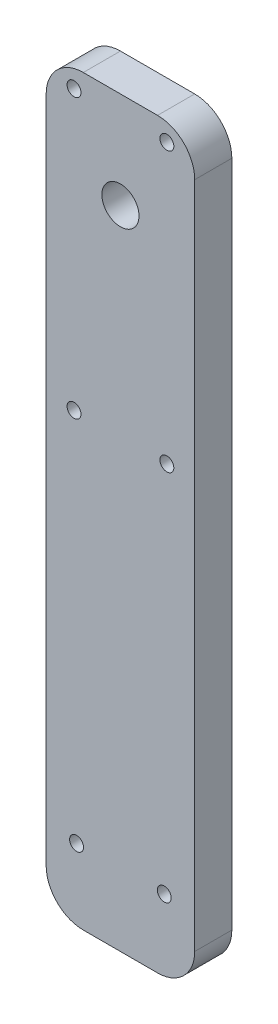
from build123d import *

# Parameters (mm, degrees)
SKETCH1_W           = 25.4
SKETCH1_H           = 127
BOSS_EXTRUDE1_DEPTH = 6.35
SKETCH2_R           = 1.190625
CUT_EXTRUDE1_DEPTH  = 6.35
FILLET1_R           = 6.35
SKETCH3_R           = 3.175
CUT_EXTRUDE2_DEPTH  = 6.35
SKETCH4_R           = 1.190625
CUT_EXTRUDE3_DEPTH  = 6.35


with BuildPart() as part:
    # Sketch1 → Boss-Extrude1 (new body)
    with BuildSketch(Plane.XY):
        with Locations((12.7, 63.5)):
            Rectangle(SKETCH1_W, SKETCH1_H)
    extrude(amount=BOSS_EXTRUDE1_DEPTH)

    # Sketch2 → Cut-Extrude1 (cut)
    with BuildSketch(Plane.XY.offset(6.35)):
        with Locations((5.2, 12.2625)):
            Circle(SKETCH2_R)
        with Locations((20.2, 12.2625)):
            Circle(SKETCH2_R)
    extrude(amount=-CUT_EXTRUDE1_DEPTH, mode=Mode.SUBTRACT)

    # Fillet1
    fillet1_edges = [part.edges().sort_by_distance(p)[0] for p in [
        (0, 127, 3.175),
        (25.4, 127, 3.175),
        (25.4, 0, 3.175),
        (0, 0, 3.175),
    ]]
    fillet(fillet1_edges, radius=FILLET1_R)

    # Sketch3 → Cut-Extrude2 (cut)
    with BuildSketch(Plane.XY.offset(6.35)):
        with Locations((12.7, 110.49991)):
            Circle(SKETCH3_R)
    extrude(amount=-CUT_EXTRUDE2_DEPTH, mode=Mode.SUBTRACT)

    # Sketch4 → Cut-Extrude3 (cut)
    with BuildSketch(Plane.XY.offset(6.35)):
        with Locations((4.7625, 123.8123)):
            Circle(SKETCH4_R)
        with Locations((20.6375, 123.8123)):
            Circle(SKETCH4_R)
        with Locations((20.6375, 76.1873)):
            Circle(SKETCH4_R)
        with Locations((4.7625, 76.1873)):
            Circle(SKETCH4_R)
    extrude(amount=-CUT_EXTRUDE3_DEPTH, mode=Mode.SUBTRACT)


solid = part.part
